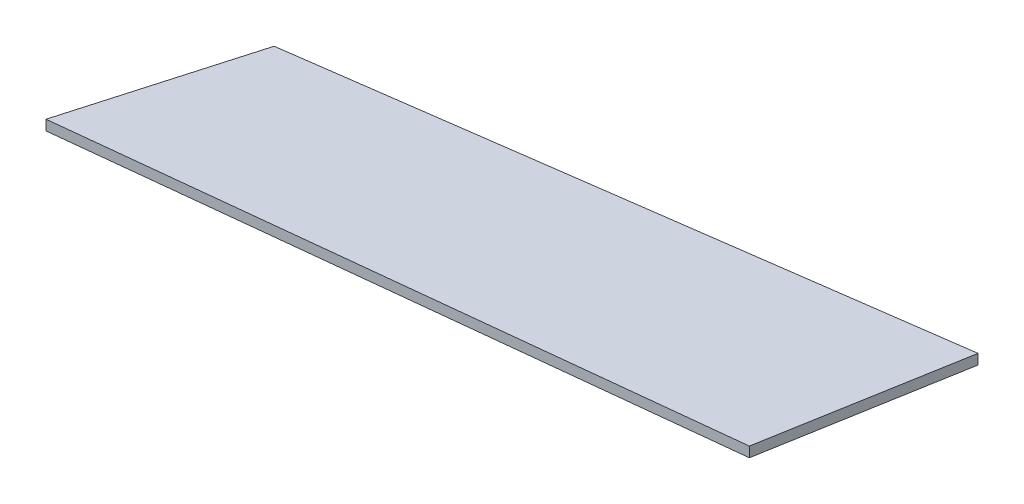
from build123d import *

# Parameters (mm, degrees)
BOSS_EXTRU_1_DEPTH = 2


with BuildPart() as part:
    # Esquisse1 → Boss.-Extru.1 (new body)
    with BuildSketch(Plane(origin=(0, 0, 0), x_dir=(1, 0, 0), z_dir=(0, 1, 0))):
        Polygon((131.88771718, 51.913810721), (10.023262283, 34.959134073), (0, 0), (125.174664551, 13.534361738), align=None)
    extrude(amount=BOSS_EXTRU_1_DEPTH)


solid = part.part
